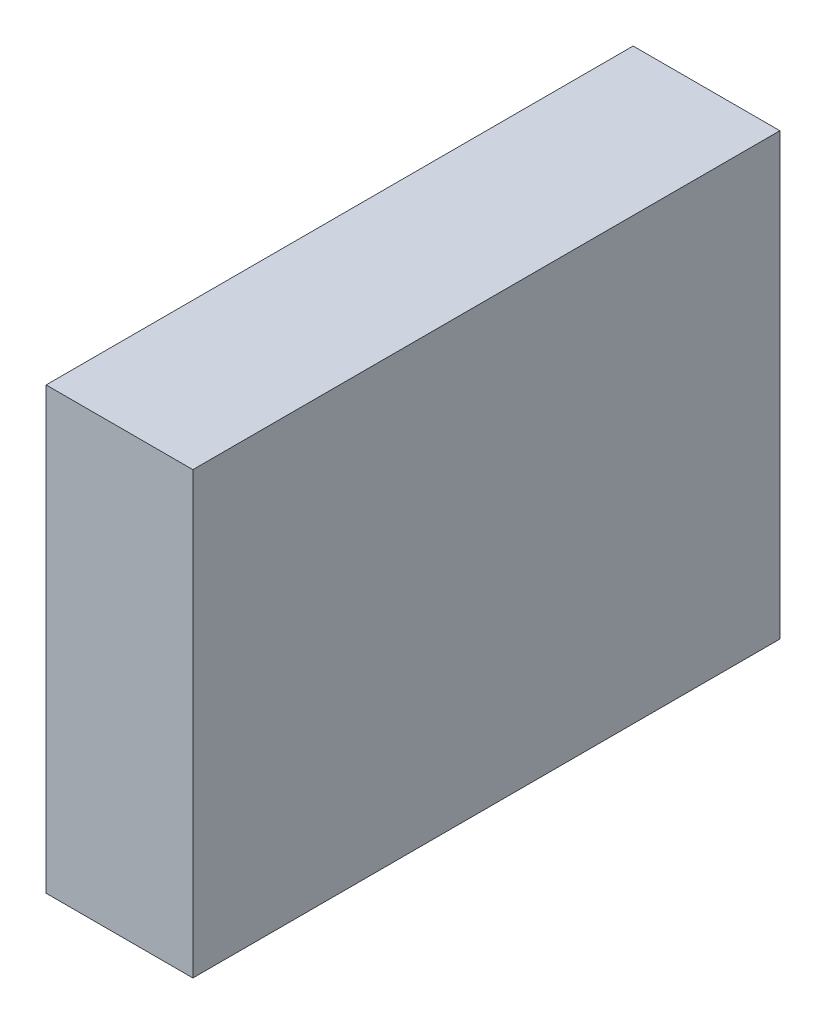
from build123d import *

# Parameters (mm, degrees)
SKETCH4_W           = 10
SKETCH4_H           = 40
BOSS_EXTRUDE2_DEPTH = 30


with BuildPart() as part:
    # Sketch4 → Boss-Extrude2 (new body)
    with BuildSketch(Plane(origin=(0, 0, 0), x_dir=(1, 0, 0), z_dir=(0, 1, 0))):
        with Locations((5, 20)):
            Rectangle(SKETCH4_W, SKETCH4_H)
    extrude(amount=BOSS_EXTRUDE2_DEPTH)


solid = part.part
